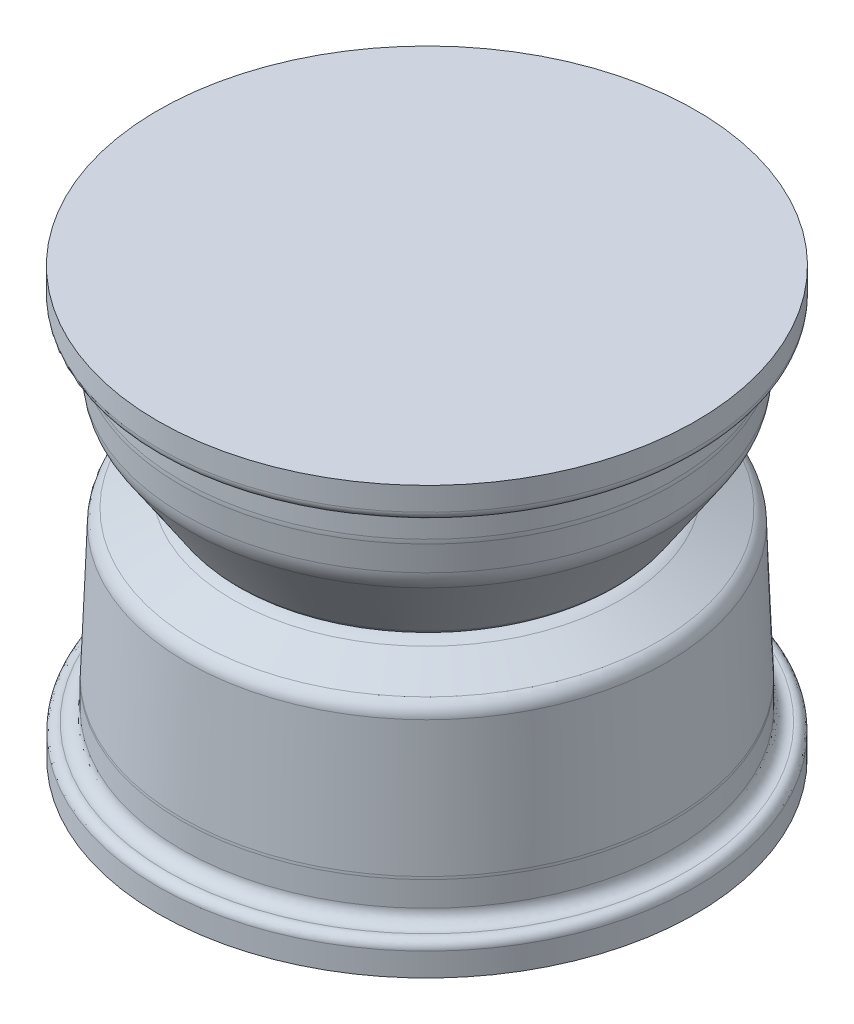
from build123d import *


with BuildPart() as part:
    # Sketch1 → Revolve1 (revolve)
    with BuildSketch(Plane(origin=(0, 0, 0), x_dir=(0, 0, -1), z_dir=(1, 0, 0))):
        with BuildLine():
            Line((-138.555289406, 98.365316059), (-138.555289406, 110.365316059))
            Line((-138.555289406, 110.365316059), (0, 110.365316059))
            Line((0, 110.365316059), (0, -109.400182818))
            Line((0, -109.400182818), (-138.42748794, -109.400182818))
            Line((-138.42748794, -109.400182818), (-138.42748794, -97.400182818))
            add(Edge.make_bspline(
                [(-133.5197355, -93.124708626), (-136.705561076, -92.67290135), (-138.42748794, -95.005060825), (-138.42748794, -97.400182818)],
                knots=[0, 0, 0, 0, 1, 1, 1, 1], degree=3, weights=[0.255591692, 0.242825015, 0.327183181, 0.50866619]))
            add(Edge.make_bspline(
                [(-133.5197355, -93.124708626), (-128.834697888, -93.789131091), (-126.3024525, -90.359484804), (-126.3024525, -86.837246579)],
                knots=[0, 0, 0, 0, 1, 1, 1, 1], degree=3, weights=[0.255591692, 0.242825015, 0.327183181, 0.50866619]))
            Line((-126.3024525, -86.837246579), (-126.3024525, -81.41085095))
            Line((-126.3024525, -81.41085095), (-126.3024525, -74.082885282))
            ThreePointArc((-126.3024525, -74.082885282), (-126.296002424, -73.410974798), (-126.276654574, -72.739311964))
            Line((-126.276654574, -72.739311964), (-123.66176318, -4.671764925))
            ThreePointArc((-123.66176318, -4.671764925), (-122.333578486, -0.555573521), (-119.056955539, 2.267695562))
            Line((-119.056955539, 2.267695562), (-99.825500253, 11.262454717))
            add(Edge.make_bspline(
                [(-91.798775, 13.047291374), (-94.605850649, 13.047291374), (-97.322433085, 12.433166241), (-99.825500253, 11.262454717)],
                knots=[0, 0, 0, 0, 1, 1, 1, 1], degree=3, weights=[0.254333095, 0.254333095, 0.258499794, 0.266833191]))
            Line((-91.798775, 13.047291374), (-91.186, 13.047291374))
            ThreePointArc((-91.186, 13.047291374), (-94.925670916, 13.983450953), (-97.783218052, 16.571105814))
            Line((-97.783218052, 16.571105814), (-122.246455667, 53.136762929))
            ThreePointArc((-122.246455667, 53.136762929), (-124.382440282, 57.404541307), (-125.39064134, 62.069291374))
            Line((-125.39064134, 62.069291374), (-126.585845332, 75.730535508))
            ThreePointArc((-126.585845332, 75.730535508), (-126.658324828, 76.836358935), (-126.6825, 77.944291374))
            Line((-126.6825, 77.944291374), (-126.6825, 87.501121148))
            ThreePointArc((-126.6825, 87.501121148), (-128.772790503, 92.210407188), (-133.6675, 93.819291374))
            ThreePointArc((-133.6675, 93.819291374), (-137.139237072, 94.987189383), (-138.555289406, 98.365316059))
        make_face()
    revolve(axis=Axis((0, 55, 0), (0, -1, 0)))


solid = part.part
